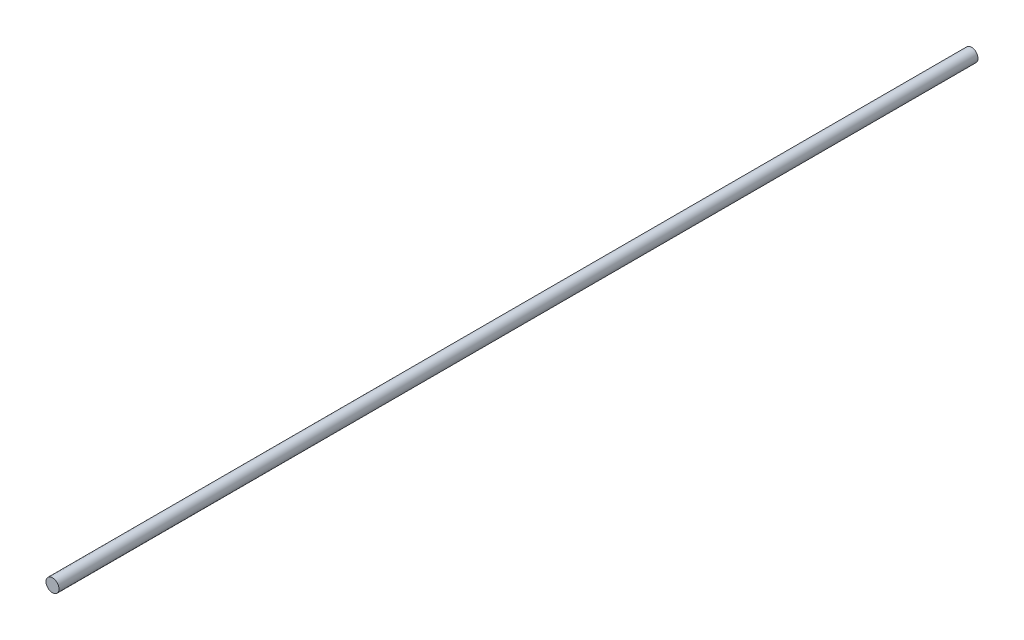
from build123d import *

# Parameters (mm, degrees)
ESQUISSE1_R        = 4
BOSS_EXTRU_1_DEPTH = 565


with BuildPart() as part:
    # Esquisse1 → Boss.-Extru.1 (new body)
    with BuildSketch(Plane.XY):
        Circle(ESQUISSE1_R)
    extrude(amount=BOSS_EXTRU_1_DEPTH)


solid = part.part
